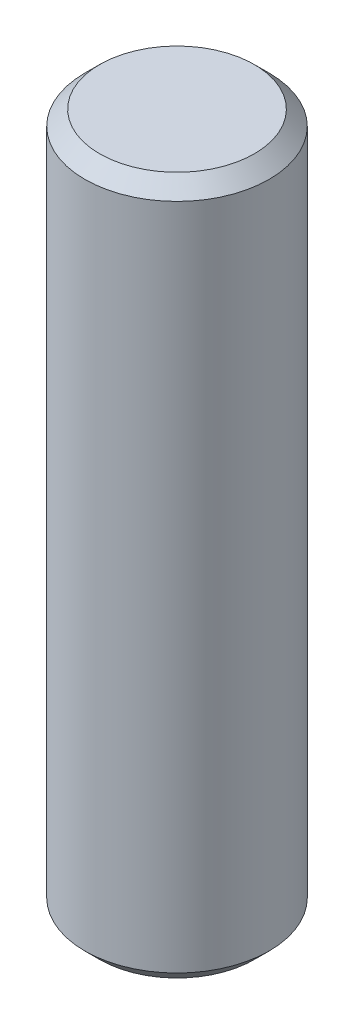
from build123d import *

# Parameters (mm, degrees)
SKETCH1_R           = 3.16865
BOSS_EXTRUDE1_DEPTH = 24
CHAMFER1_SIZE       = 0.508


with BuildPart() as part:
    # Sketch1 → Boss-Extrude1 (new body)
    with BuildSketch(Plane(origin=(0, 0, 0), x_dir=(1, 0, 0), z_dir=(0, 1, 0))):
        with Locations(Location((0, 0, 0), (0, 0, 270))):  # turned: the seam where the file's is
            Circle(SKETCH1_R)
    extrude(amount=BOSS_EXTRUDE1_DEPTH)

    # Chamfer1
    chamfer1_edges = [part.edges().sort_by_distance(p)[0] for p in [
        (0, 0, -3.16865),
        (0, 24, -3.16865),
    ]]
    chamfer(chamfer1_edges, length=CHAMFER1_SIZE)


solid = part.part
